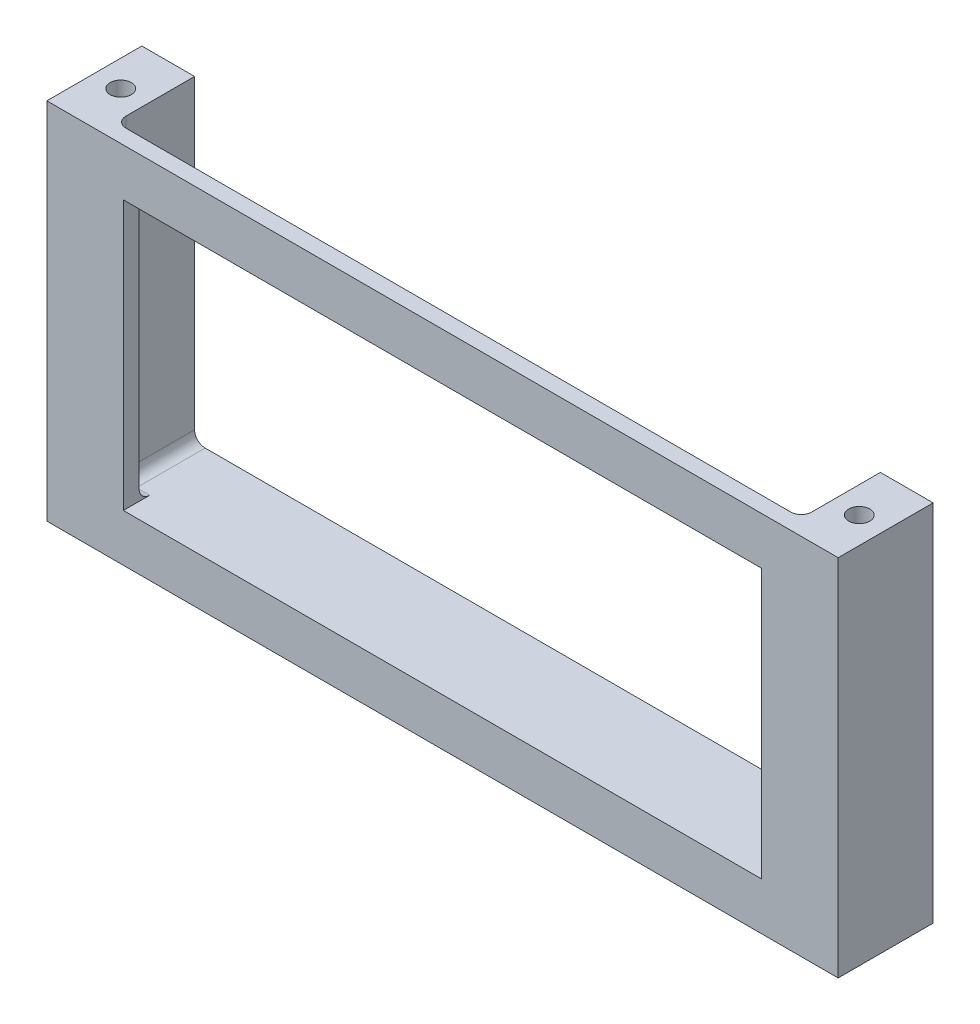
from build123d import *

# Parameters (mm, degrees)
SKETCH1_W                = 130
SKETCH1_H                = 3
BOSS_EXTRUDE1_DEPTH      = 69
SKETCH2_W                = 121
SKETCH2_H                = 51
CUT_EXTRUDE1_DEPTH       = 65
BOSS_EXTRUDE3_DEPTH      = 15
BOSS_EXTRUDE3_DEPTH_BACK = 3
SKETCH4_R                = 2
CUT_EXTRUDE2_DEPTH       = 70
FILLET1_R                = 2
FILLET2_R                = 2


with BuildPart() as part:
    # Sketch1 → Boss-Extrude1 (new body)
    with BuildSketch(Plane(origin=(0, 0, 0), x_dir=(1, 0, 0), z_dir=(0, 1, 0))):
        Rectangle(SKETCH1_W, SKETCH1_H)
    extrude(amount=BOSS_EXTRUDE1_DEPTH)

    # Sketch2 → Cut-Extrude1 (cut)
    with BuildSketch(Plane.XY.offset(1.5)):
        with Locations((0, 34.5)):
            Rectangle(SKETCH2_W, SKETCH2_H)
    extrude(amount=-CUT_EXTRUDE1_DEPTH, mode=Mode.SUBTRACT)

    # Sketch3 → Boss-Extrude3 (add, two sides)
    with BuildSketch(Plane(origin=(0, 0, -1.5), x_dir=(-1, 0, 0), z_dir=(0, 0, -1))) as boss_extrude3_sk:
        Polygon((75, 0), (-75, 0), (-75, 69), (-65, 69), (-65, 9), (65, 9), (65, 69), (75, 69), align=None)
    extrude(amount=BOSS_EXTRUDE3_DEPTH)
    extrude(boss_extrude3_sk.sketch, amount=-BOSS_EXTRUDE3_DEPTH_BACK)

    # Sketch4 → Cut-Extrude2 (cut, through all)
    with BuildSketch(Plane(origin=(0, 69, 0), x_dir=(1, 0, 0), z_dir=(0, 1, 0))):
        with Locations((-70, 7.5)):
            Circle(SKETCH4_R)
        with Locations((70, 7.5)):
            Circle(SKETCH4_R)
    extrude(amount=-CUT_EXTRUDE2_DEPTH, mode=Mode.SUBTRACT)

    # Fillet1
    fillet1_edges = [part.edges().sort_by_distance(p)[0] for p in [
        (-65, 9, -9),
        (65, 9, -9),
    ]]
    fillet(fillet1_edges, radius=FILLET1_R)

    # Fillet2
    fillet2_edges = [part.edges().sort_by_distance(p)[0] for p in [
        (-61.75, 9, -1.5),
        (-65, 40, -1.5),
        (61.75, 9, -1.5),
        (65, 40, -1.5),
        (-64.414213562, 9.585786438, -1.5),
        (64.414213562, 9.585786438, -1.5),
    ]]
    fillet(fillet2_edges, radius=FILLET2_R)


solid = part.part
